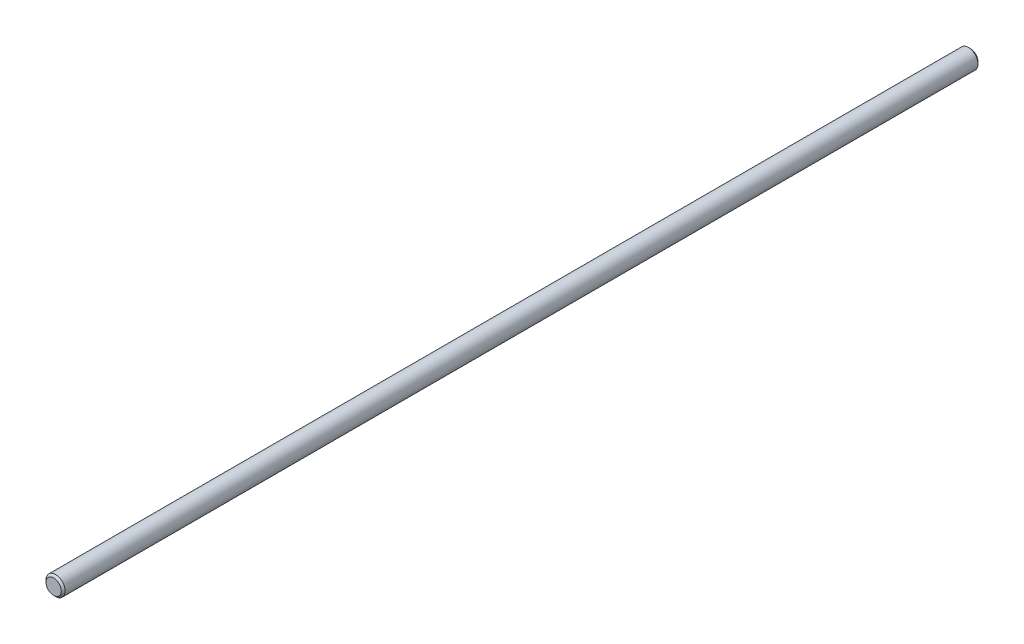
from build123d import *

# Parameters (mm, degrees)
SKETCH1_R      = 3.175
EXTRUDE1_DEPTH = 152.4
CHAMFER1_SIZE  = 0.635


with BuildPart() as part:
    # Sketch1 → Extrude1 (new body, symmetric)
    with BuildSketch(Plane.XY):
        Circle(SKETCH1_R)
    extrude(amount=EXTRUDE1_DEPTH, both=True)

    # Chamfer1
    chamfer1_edges = [part.edges().sort_by_distance(p)[0] for p in [
        (-3.175, 0, -152.4),
        (-3.175, 0, 152.4),
    ]]
    chamfer(chamfer1_edges, length=CHAMFER1_SIZE)


solid = part.part
